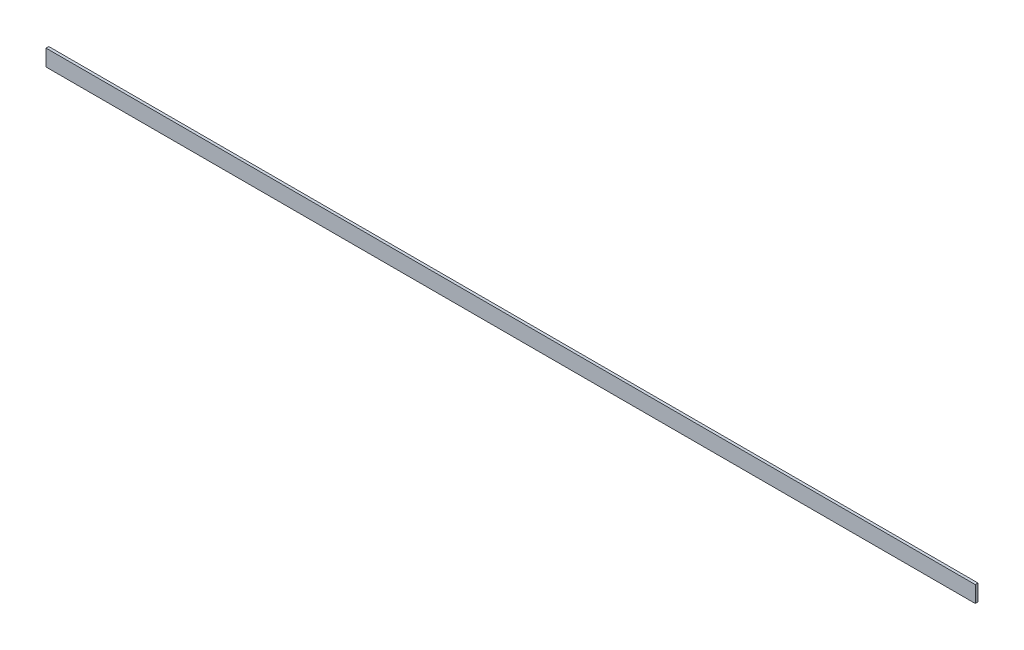
from build123d import *

# Parameters (mm, degrees)
SKETCH_1_W      = 5
SKETCH_1_H      = 30
EXTRUDE_1_DEPTH = 1700


with BuildPart() as part:
    # Эскиз1 → Бобышка-Вытянуть1 (new body)
    with BuildSketch(Plane(origin=(0, 0, 0), x_dir=(0, 0, -1), z_dir=(1, 0, 0))):
        with Locations((2.5, 15)):
            Rectangle(SKETCH_1_W, SKETCH_1_H)
    extrude(amount=EXTRUDE_1_DEPTH)


solid = part.part
